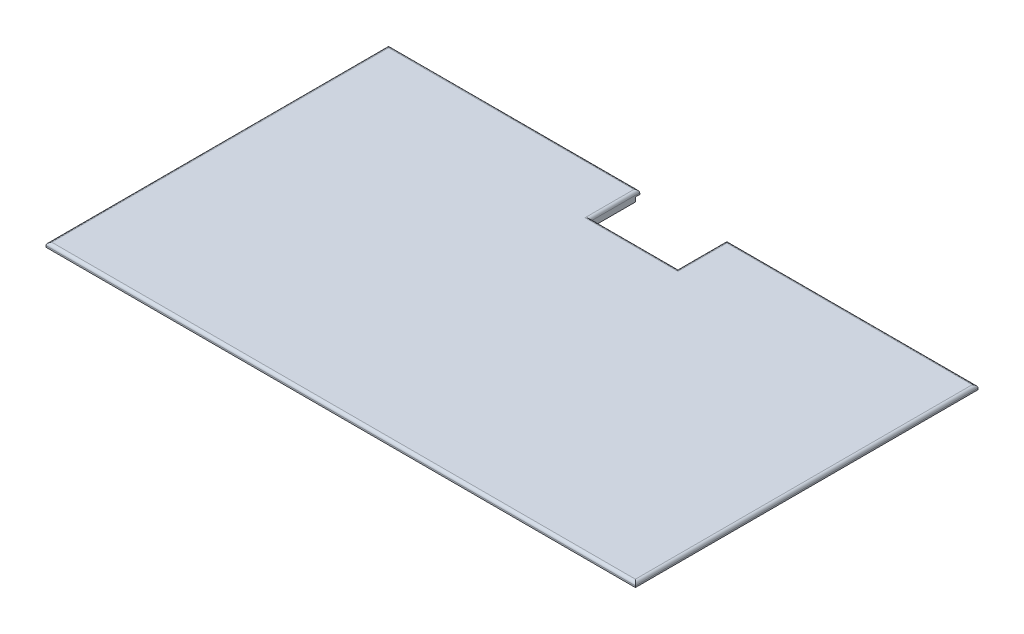
from build123d import *

# Parameters (mm, degrees)
SKETCH_1_W          = 200
SKETCH_1_H          = 115
EXTRUDE_1_DEPTH     = 1.5
SKETCH_2_W          = 203
SKETCH_2_H          = 118
EXTRUDE_2_DEPTH     = 1.5
SKETCH_3_W          = 30
SKETCH_3_H          = 18.47287918
CUT_EXTRUDE_1_DEPTH = 11.5
FILLET_3_R          = 1


with BuildPart() as part:
    # 草图1 → 凸台-拉伸1 (new body)
    with BuildSketch(Plane(origin=(0, 0, 0), x_dir=(1, 0, 0), z_dir=(0, 1, 0))):
        Rectangle(SKETCH_1_W, SKETCH_1_H)
    extrude(amount=EXTRUDE_1_DEPTH)

    # 草图2 → 凸台-拉伸2 (add)
    with BuildSketch(Plane(origin=(0, 1.5, 0), x_dir=(1, 0, 0), z_dir=(0, 1, 0))):
        Rectangle(SKETCH_2_W, SKETCH_2_H)
    extrude(amount=EXTRUDE_2_DEPTH)

    # 草图3 → 切除-拉伸1 (cut)
    with BuildSketch(Plane.XZ):
        with Locations((0, -51.38442851)):
            Rectangle(SKETCH_3_W, SKETCH_3_H)
    extrude(amount=-CUT_EXTRUDE_1_DEPTH, mode=Mode.SUBTRACT)

    # 圆角3
    fillet_3_edges = [part.edges().sort_by_distance(p)[0] for p in [
        (101.5, 3, 0),
        (58.25, 3, -59),
        (-101.5, 3, 0),
        (0, 3, 59),
        (-58.25, 3, -59),
        (0, 3, -42.14798892),
        (15, 3, -50.57399446),
        (-15, 3, -50.57399446),
    ]]
    fillet(fillet_3_edges, radius=FILLET_3_R)


solid = part.part
